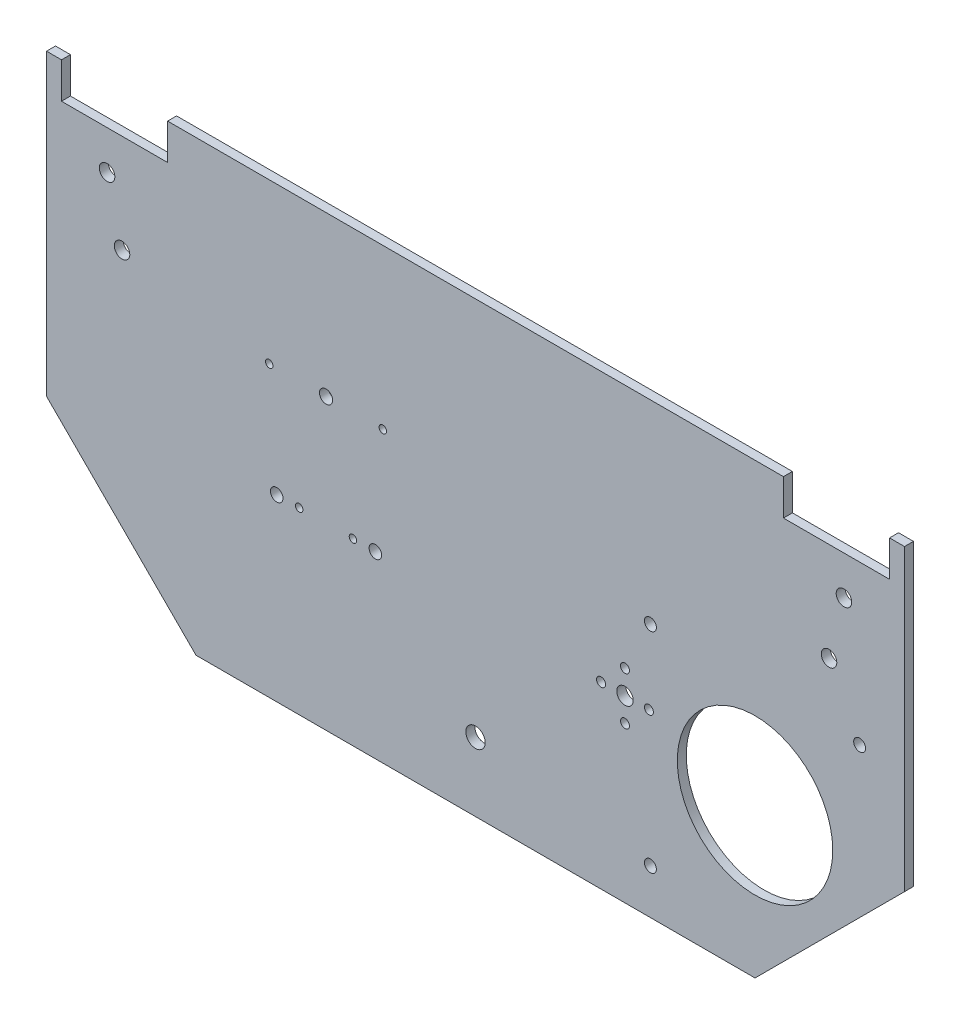
from build123d import *

# Parameters (mm, degrees)
MODEL_R             = 2.6
MODEL_R_2           = 1.25
MODEL_R_3           = 2.2
MODEL_R_4           = 2.1
MODEL_R_5           = 2.75
MODEL_R_6           = 1.5
MODEL_R_7           = 3.25
MODEL_R_8           = 26
BOSS_EXTRUDE1_DEPTH = 3
SKETCH1_R           = 2
CUT_EXTRUDE1_DEPTH  = 4


with BuildPart() as part:
    # Model → Boss-Extrude1 (new body)
    with BuildSketch(Plane.XY):
        Polygon((5, 150), (0, 150), (0, 50), (50, 0), (237, 0), (287, 50), (287, 150), (282, 150), (282, 138), (246.5, 138), (246.5, 150), (40.5, 150), (40.5, 138), (5, 138), align=None)
        with Locations((266.75, 125)):
            Circle(MODEL_R, mode=Mode.SUBTRACT)
        with Locations((261.75, 105)):
            Circle(MODEL_R, mode=Mode.SUBTRACT)
        with Locations((25.25, 105)):
            Circle(MODEL_R, mode=Mode.SUBTRACT)
        with Locations((20.25, 125)):
            Circle(MODEL_R, mode=Mode.SUBTRACT)
        with Locations((74.5, 96.7)):
            Circle(MODEL_R_2, mode=Mode.SUBTRACT)
        with Locations((93.5, 96.7)):
            Circle(MODEL_R_3, mode=Mode.SUBTRACT)
        with Locations((110, 60)):
            Circle(MODEL_R_4, mode=Mode.SUBTRACT)
        with Locations((77, 60)):
            Circle(MODEL_R_4, mode=Mode.SUBTRACT)
        with Locations((84.5, 60)):
            Circle(MODEL_R_2, mode=Mode.SUBTRACT)
        with Locations((102.5, 60)):
            Circle(MODEL_R_2, mode=Mode.SUBTRACT)
        with Locations((112.5, 96.7)):
            Circle(MODEL_R_2, mode=Mode.SUBTRACT)
        with Locations((193.5, 60)):
            Circle(MODEL_R_5, mode=Mode.SUBTRACT)
        with Locations((201.5, 60)):
            Circle(MODEL_R_6, mode=Mode.SUBTRACT)
        with Locations((185.5, 60)):
            Circle(MODEL_R_6, mode=Mode.SUBTRACT)
        with Locations((143.5, 23)):
            Circle(MODEL_R_7, mode=Mode.SUBTRACT)
        with Locations((193.5, 68)):
            Circle(MODEL_R_6, mode=Mode.SUBTRACT)
        with Locations((193.5, 52)):
            Circle(MODEL_R_6, mode=Mode.SUBTRACT)
        with Locations((237, 50)):
            Circle(MODEL_R_8, mode=Mode.SUBTRACT)
    extrude(amount=BOSS_EXTRUDE1_DEPTH)

    # Sketch1 → Cut-Extrude1 (cut, through all)
    with BuildSketch(Plane(origin=(0, 0, 0), x_dir=(-1, 0, 0), z_dir=(0, 0, -1))):
        with Locations((-202, 85)):
            Circle(SKETCH1_R)
        with Locations((-202, 15)):
            Circle(SKETCH1_R)
        with Locations((-272, 85)):
            Circle(SKETCH1_R)
    extrude(amount=-CUT_EXTRUDE1_DEPTH, mode=Mode.SUBTRACT)


solid = part.part
